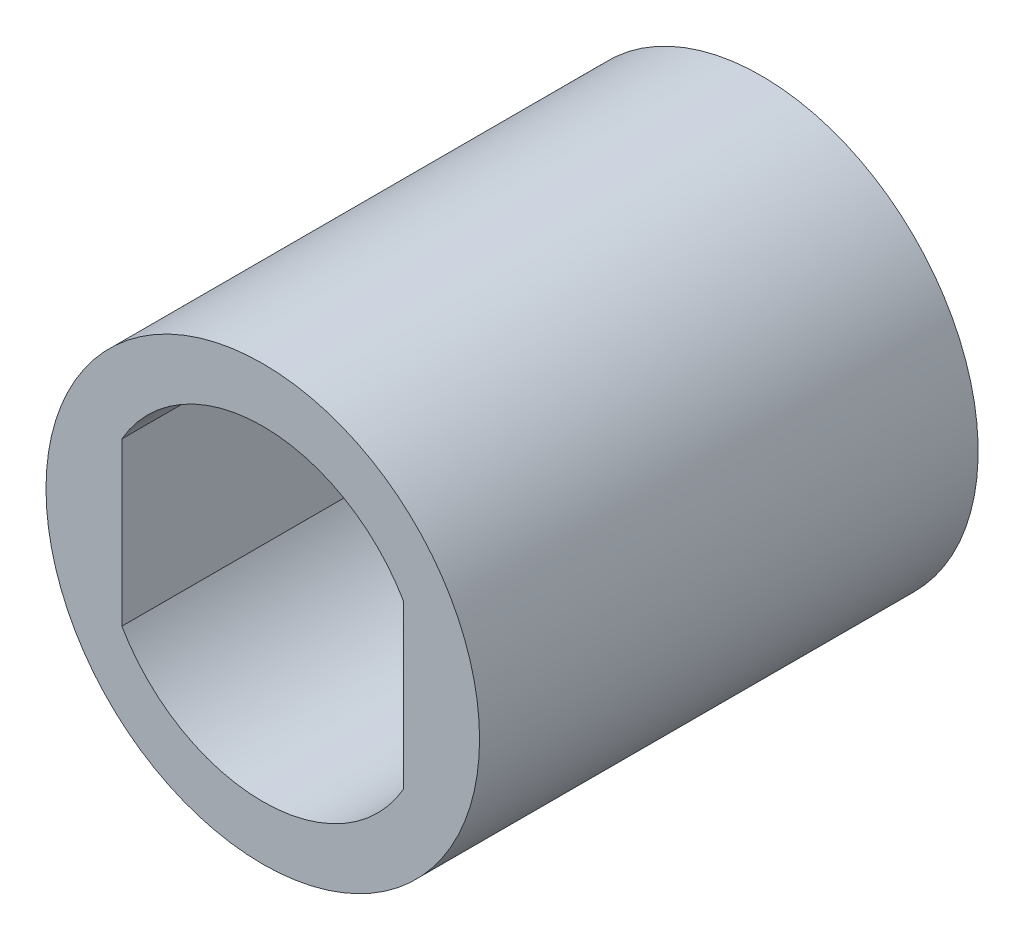
from build123d import *

# Parameters (mm, degrees)
SKETCH1_R           = 10
BOSS_EXTRUDE1_DEPTH = 18
SKETCH2_R           = 10
SKETCH2_R_2         = 4
BOSS_EXTRUDE2_DEPTH = 5


with BuildPart() as part:
    # Sketch1 → Boss-Extrude1 (new body)
    with BuildSketch(Plane.XY):
        Circle(SKETCH1_R)
        with BuildLine():
            Line((-6.5, 3.741657387), (-6.5, -3.741657387))
            ThreePointArc((-6.5, -3.741657387), (0, -7.5), (6.5, -3.741657387))
            Line((6.5, -3.741657387), (6.5, 3.741657387))
            ThreePointArc((6.5, 3.741657387), (0, 7.5), (-6.5, 3.741657387))
        make_face(mode=Mode.SUBTRACT)
    extrude(amount=BOSS_EXTRUDE1_DEPTH)

    # Sketch2 → Boss-Extrude2 (add)
    with BuildSketch(Plane(origin=(0, 0, 0), x_dir=(-1, 0, 0), z_dir=(0, 0, -1))):
        Circle(SKETCH2_R)
        Circle(SKETCH2_R_2, mode=Mode.SUBTRACT)
    extrude(amount=BOSS_EXTRUDE2_DEPTH)


solid = part.part
